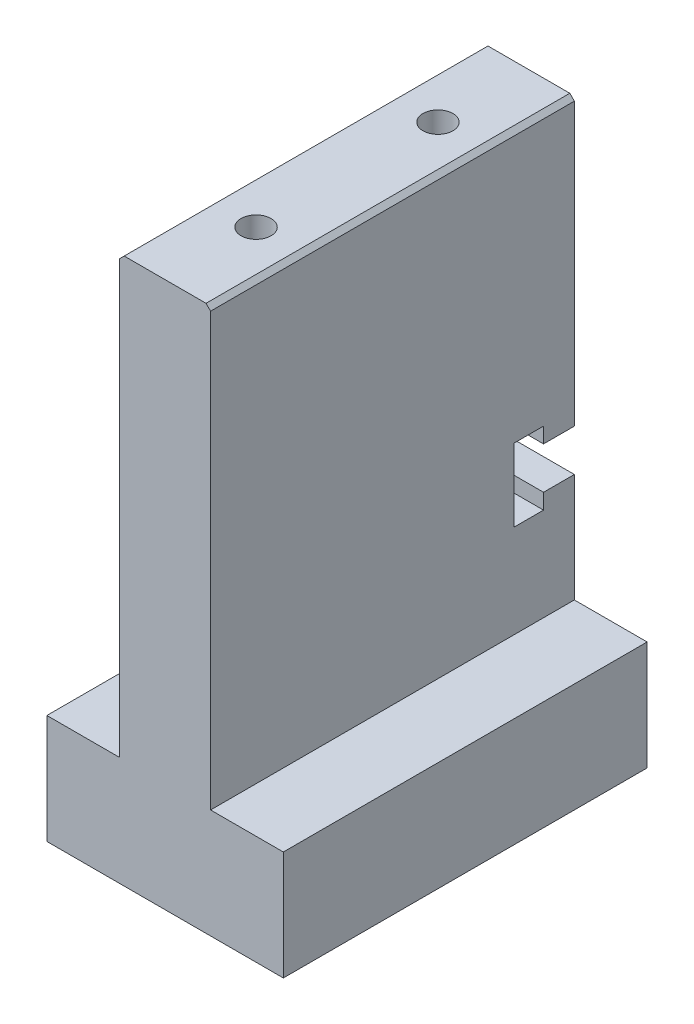
from build123d import *

# Parameters (mm, degrees)
SKETCH1_W             = 26
SKETCH1_H             = 12
BOSS_EXTRUDE1_DEPTH   = 40
SKETCH2_W             = 10
SKETCH2_H             = 40
BOSS_EXTRUDE2_DEPTH   = 48
CUT_EXTRUDE1_DEPTH    = 48
M3_TAPPED_HOLE1_D     = 2.5
M3_TAPPED_HOLE1_DEPTH = 6
M3_TAPPED_HOLE1_TIP   = 0.751075774
M4_TAPPED_HOLE1_D     = 3.3
M4_TAPPED_HOLE1_DEPTH = 8
M4_TAPPED_HOLE1_TIP   = 0.991420021
CHAMFER1_SIZE         = 0.5


with BuildPart() as part:
    # Sketch1 → Boss-Extrude1 (new body)
    with BuildSketch(Plane.XY):
        with Locations((2.110588235, -0.708235294)):
            Rectangle(SKETCH1_W, SKETCH1_H)
    extrude(amount=BOSS_EXTRUDE1_DEPTH)

    # Sketch2 → Boss-Extrude2 (add)
    with BuildSketch(Plane(origin=(0, 5.291764706, 0), x_dir=(1, 0, 0), z_dir=(0, 1, 0))):
        with Locations((2.110588235, -20)):
            Rectangle(SKETCH2_W, SKETCH2_H)
    extrude(amount=BOSS_EXTRUDE2_DEPTH)

    # Sketch3 → Cut-Extrude1 (cut)
    with BuildSketch(Plane.ZY.offset(2.889411765)):
        Polygon((0, 21.841764706), (3.389763468, 21.841764706), (3.389763468, 23.541764706), (6.66389663, 23.541764706), (6.66389663, 15.541764706), (3.389763468, 15.541764706), (3.389763468, 17.241764706), (0, 17.241764706), align=None)
    extrude(amount=-CUT_EXTRUDE1_DEPTH, mode=Mode.SUBTRACT)

    # M3 Tapped Hole1
    with Locations(Plane(origin=(0, 0, 0), x_dir=(-1, 0, 0), z_dir=(0, 0, -1))):
        with Locations((-9.110588235, -0.708235294), (4.889411765, -0.708235294), (-2.110588235, 51.291764706)):
            Hole(M3_TAPPED_HOLE1_D / 2, depth=M3_TAPPED_HOLE1_DEPTH)
            with Locations((0, 0, -(M3_TAPPED_HOLE1_DEPTH + M3_TAPPED_HOLE1_TIP / 2))):  # 118° drill point
                Cone(0, M3_TAPPED_HOLE1_D / 2, M3_TAPPED_HOLE1_TIP, mode=Mode.SUBTRACT)

    # M4 Tapped Hole1
    with Locations(Plane(origin=(0, 53.291764706, 0), x_dir=(1, 0, 0), z_dir=(0, 1, 0))):
        with Locations((2.110588235, -10), (2.110588235, -30)):
            Hole(M4_TAPPED_HOLE1_D / 2, depth=M4_TAPPED_HOLE1_DEPTH)
            with Locations((0, 0, -(M4_TAPPED_HOLE1_DEPTH + M4_TAPPED_HOLE1_TIP / 2))):  # 118° drill point
                Cone(0, M4_TAPPED_HOLE1_D / 2, M4_TAPPED_HOLE1_TIP, mode=Mode.SUBTRACT)

    # Chamfer1
    chamfer1_edges = [part.edges().sort_by_distance(p)[0] for p in [
        (-2.889411765, 53.291764706, 20),
        (7.110588235, 53.291764706, 20),
    ]]
    chamfer(chamfer1_edges, length=CHAMFER1_SIZE)


solid = part.part
